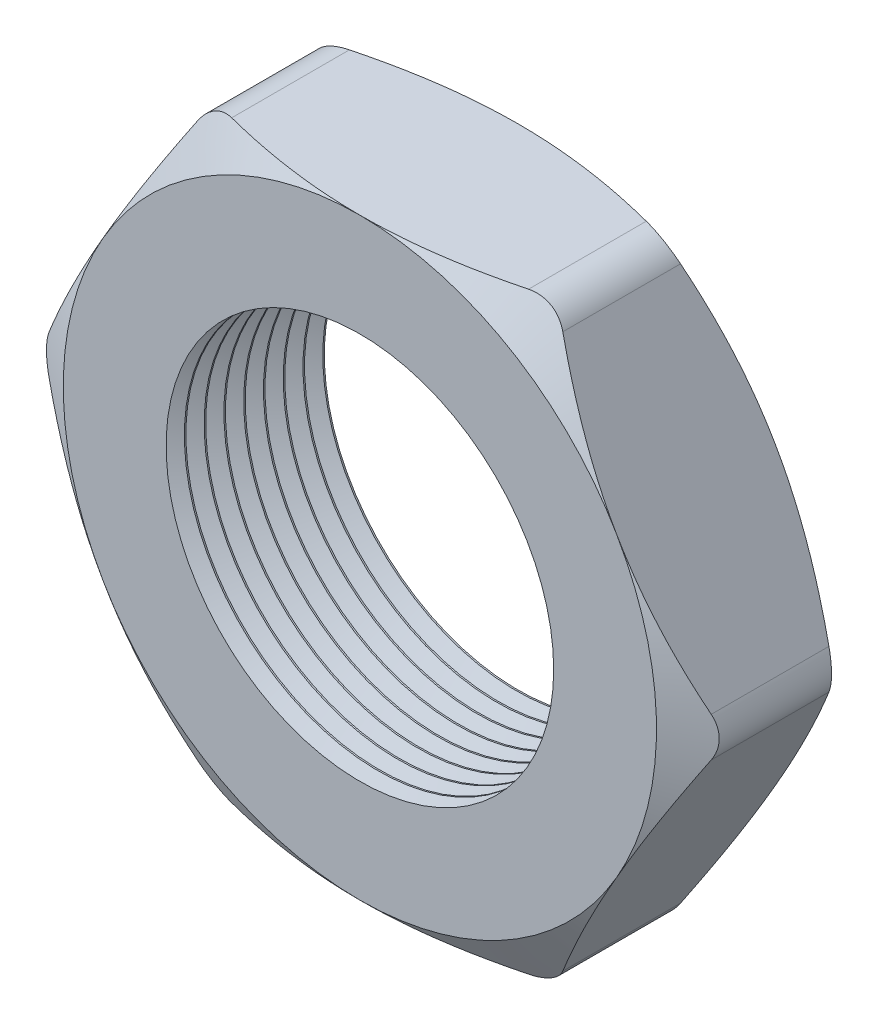
from build123d import *

# Parameters (mm, degrees)
SKETCH1_R          = 6.223
EXTRUDE1_DEPTH     = 5.08
SKETCH2_OUTSIDE_W  = 50.968
SKETCH2_OUTSIDE_H  = 48.02
SKETCH2_OUTSIDE_R  = 9.525
CUT_EXTRUDE1_DEPTH = 6.08
CUT_EXTRUDE1_DRAFT = -60
SKETCH3_OUTSIDE_W  = 50.968
SKETCH3_OUTSIDE_H  = 48.02
SKETCH3_OUTSIDE_R  = 9.525
CUT_EXTRUDE2_DEPTH = 6.08
CUT_EXTRUDE2_DRAFT = -60
FILLET1_R          = 1.27
LPATTERN1_COUNT    = 8
LPATTERN1_PITCH    = 0.635


with BuildPart() as part:
    # Sketch1 → Extrude1 (new body)
    with BuildSketch(Plane.XY):
        Polygon((-10.998522628, 0), (-5.499261314, -9.525), (5.499261314, -9.525), (10.998522628, 0), (5.499261314, 9.525), (-5.499261314, 9.525), align=None)
        Circle(SKETCH1_R, mode=Mode.SUBTRACT)
    extrude(amount=EXTRUDE1_DEPTH)


with BuildPart() as cut_extrude1_tool:
    # Sketch2 outside → Cut-Extrude1 (with draft: the straight prism first)
    with BuildSketch(Plane.XY.offset(5.08)):
        Rectangle(SKETCH2_OUTSIDE_W, SKETCH2_OUTSIDE_H)
        Circle(SKETCH2_OUTSIDE_R, mode=Mode.SUBTRACT)
    extrude(amount=-CUT_EXTRUDE1_DEPTH)
    # Cut-Extrude1: the draft: its side faces are tilted about the plane it starts from
    cut_extrude1_sides = [cut_extrude1_tool.faces().sort_by_distance(p)[0] for p in [
        (0, -24.01, 2.04),
        (25.484, 0, 2.04),
        (0, 24.01, 2.04),
        (-25.484, 0, 2.04),
        (-9.525, 0, 2.04),
    ]]
    draft(cut_extrude1_sides, Plane.XY.offset(5.08), CUT_EXTRUDE1_DRAFT)


with BuildPart() as part_1:
    add(part.part)

    # Cut-Extrude1: cut by cut_extrude1_tool
    add(cut_extrude1_tool.part, mode=Mode.SUBTRACT)


with BuildPart() as cut_extrude2_tool:
    # Sketch3 outside → Cut-Extrude2 (with draft: the straight prism first)
    with BuildSketch(Plane(origin=(0, 0, 0), x_dir=(-1, 0, 0), z_dir=(0, 0, -1))):
        Rectangle(SKETCH3_OUTSIDE_W, SKETCH3_OUTSIDE_H)
        Circle(SKETCH3_OUTSIDE_R, mode=Mode.SUBTRACT)
    extrude(amount=-CUT_EXTRUDE2_DEPTH)
    # Cut-Extrude2: the draft: its side faces are tilted about the plane it starts from
    cut_extrude2_sides = [cut_extrude2_tool.faces().sort_by_distance(p)[0] for p in [
        (0, -24.01, 3.04),
        (-25.484, 0, 3.04),
        (0, 24.01, 3.04),
        (25.484, 0, 3.04),
        (9.525, 0, 3.04),
    ]]
    draft(cut_extrude2_sides, Plane(origin=(0, 0, 0), x_dir=(-1, 0, 0), z_dir=(0, 0, -1)), CUT_EXTRUDE2_DRAFT)


with BuildPart() as part_2:
    add(part_1.part)

    # Cut-Extrude2: cut by cut_extrude2_tool
    add(cut_extrude2_tool.part, mode=Mode.SUBTRACT)

    # Fillet1
    fillet1_edges = [part_2.edges().sort_by_distance(p)[0] for p in [
        (10.998522628, 0, 2.54),
        (5.499261314, -9.525, 2.54),
        (-5.499261314, -9.525, 2.54),
        (-10.998522628, 0, 2.54),
        (-5.499261314, 9.525, 2.54),
        (5.499261314, 9.525, 2.54),
    ]]
    fillet(fillet1_edges, radius=FILLET1_R)

    # Sketch4 → Cut-Revolve1 (revolve, cut)
    with BuildSketch(Plane(origin=(0, 0, 0), x_dir=(1, 0, 0), z_dir=(0, 1, 0)), mode=Mode.PRIVATE) as cut_revolve1_sk:
        Polygon((-6.223, -5.08), (-6.223, -4.493412127), (-6.731, -4.786706063), align=None)
    cut_revolve1 = revolve(cut_revolve1_sk.sketch.rotate(Axis((0, 0, 0), (0, 0, 1)), 180), axis=Axis((0, 0, 0), (0, 0, 1)), mode=Mode.SUBTRACT)  # turned: the seam where the file's is

    # LPattern1: Cut-Revolve1 ×8
    with Locations(*[(0, 0, -i * LPATTERN1_PITCH) for i in range(1, LPATTERN1_COUNT)]):
        add(cut_revolve1, mode=Mode.SUBTRACT)


solid = part_2.part
